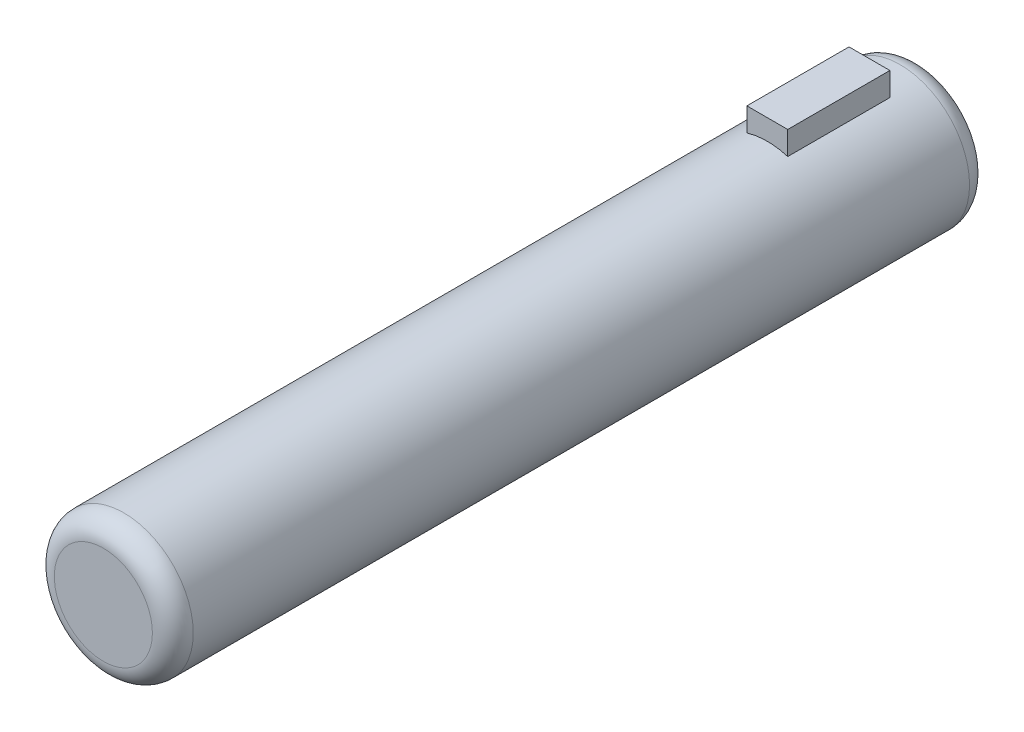
from build123d import *

# Parameters (mm, degrees)
SKETCH1_R           = 3.4
BOSS_EXTRUDE1_DEPTH = 40
FILLET2_R           = 1
BOSS_EXTRUDE2_DEPTH = 5


with BuildPart() as part:
    # Sketch1 → Boss-Extrude1 (new body)
    with BuildSketch(Plane.XY):
        Circle(SKETCH1_R)
    extrude(amount=BOSS_EXTRUDE1_DEPTH)

    # Fillet2
    fillet2_edges = [part.edges().sort_by_distance(p)[0] for p in [
        (-3.4, 0, 0),
        (-3.4, 0, 40),
    ]]
    fillet(fillet2_edges, radius=FILLET2_R)

    # Sketch2 → Boss-Extrude2 (add)
    with BuildSketch(Plane.XY.offset(2.5)):
        with BuildLine():
            Line((1, 3.249615362), (1, 4.399615362))
            Line((1, 4.399615362), (-1, 4.399615362))
            Line((-1, 4.399615362), (-1, 3.249615362))
            ThreePointArc((-1, 3.249615362), (0, 3.4), (1, 3.249615362))
        make_face()
    extrude(amount=BOSS_EXTRUDE2_DEPTH)


solid = part.part
